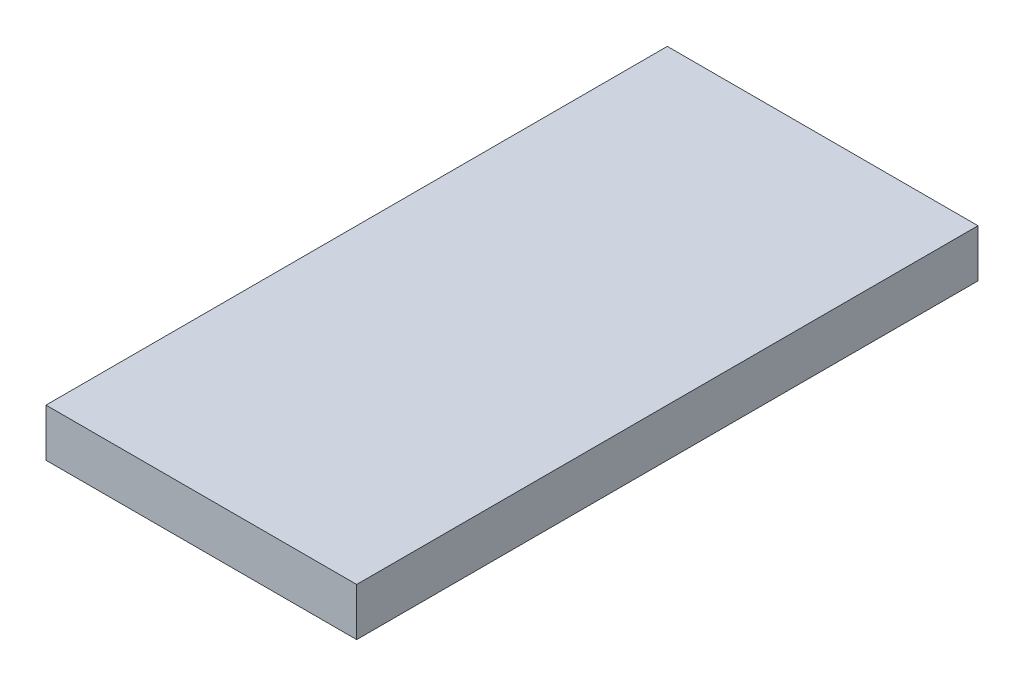
from build123d import *

# Parameters (mm, degrees)
SKETCH_1_W      = 65
SKETCH_1_H      = 130
EXTRUDE_1_DEPTH = 10


with BuildPart() as part:
    # 草图1 → 凸台-拉伸1 (new body)
    with BuildSketch(Plane(origin=(0, 0, 0), x_dir=(1, 0, 0), z_dir=(0, 1, 0))):
        Rectangle(SKETCH_1_W, SKETCH_1_H)
    extrude(amount=EXTRUDE_1_DEPTH)


solid = part.part
